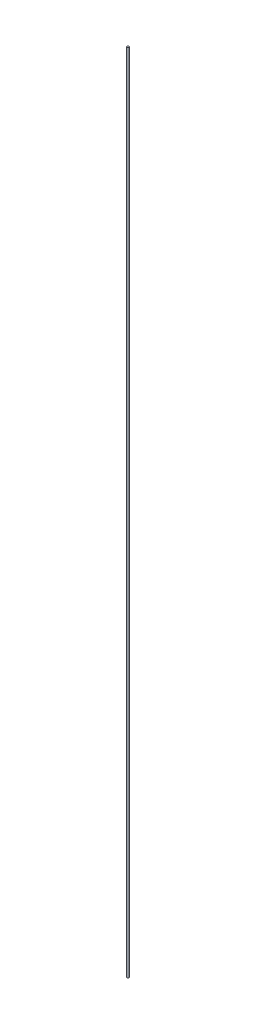
from build123d import *

# Parameters (mm, degrees)
SKETCH2_R           = 1.27
BOSS_EXTRUDE3_DEPTH = 977.9


with BuildPart() as part:
    # Sketch2 → Boss-Extrude3 (new body)
    with BuildSketch(Plane(origin=(0, 0, 0), x_dir=(1, 0, 0), z_dir=(0, 1, 0))):
        Circle(SKETCH2_R)
    extrude(amount=BOSS_EXTRUDE3_DEPTH)


solid = part.part
